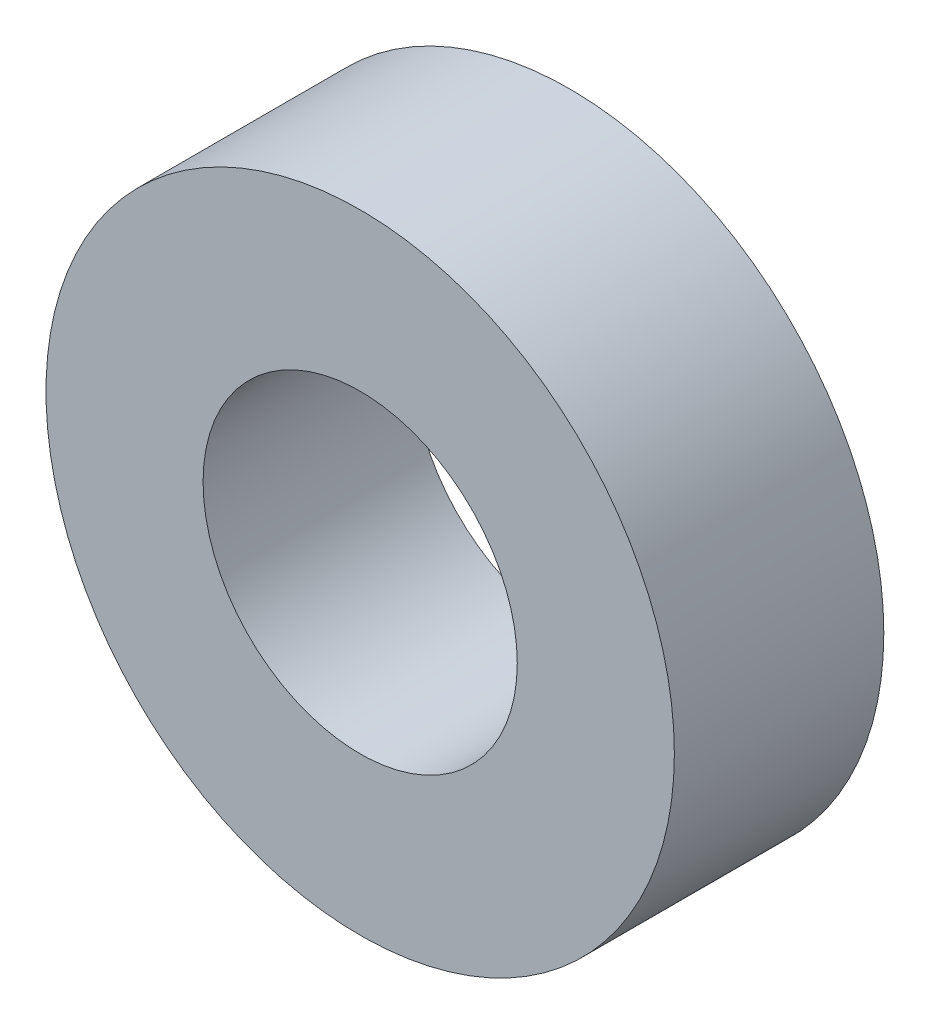
from build123d import *

# Parameters (mm, degrees)
SKETCH_1_R      = 6
SKETCH_1_R_2    = 3
EXTRUDE_1_DEPTH = 4


with BuildPart() as part:
    # 草图1 → 凸台-拉伸1 (new body)
    with BuildSketch(Plane.XY):
        Circle(SKETCH_1_R)
        Circle(SKETCH_1_R_2, mode=Mode.SUBTRACT)
    extrude(amount=EXTRUDE_1_DEPTH)


solid = part.part
